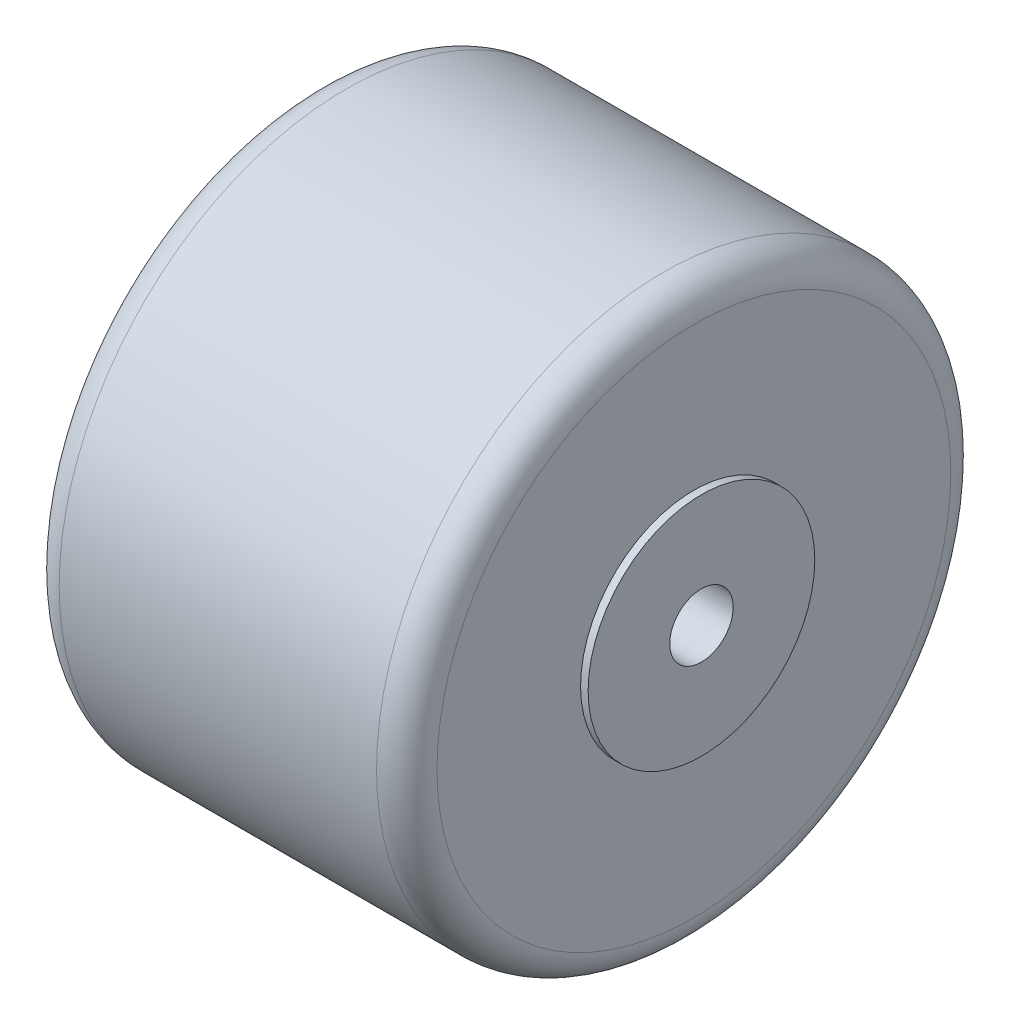
from build123d import *

# Parameters (mm, degrees)
M5_GEWINDEBOHRUNG2_D     = 4.2
M5_GEWINDEBOHRUNG2_DEPTH = 12
M5_GEWINDEBOHRUNG2_TIP   = 1.2618073
VERRUNDUNG1_R            = 2


with BuildPart() as part:
    # Skizze1 → Rotation1 (revolve)
    with BuildSketch(Plane.XY):
        Polygon((0, 0), (0, 7.5), (0.5, 7.5), (0.5, 19), (25.5, 19), (25.5, 7.5), (26, 7.5), (26, 0), align=None)
    revolve(axis=Axis((0, 0, 0), (1, 0, 0)))

    # Skizze2 → M5 Gewindebohrung1 (revolve, cut)
    with BuildSketch(Plane(origin=(26, 0, 0), x_dir=(0, 0, -1), z_dir=(0, 1, 0))):
        Polygon((0, 0), (0, 13.2618073), (2.1, 12), (2.1, 0), align=None)
    revolve(axis=Axis((32.35, 0, 0), (-1, 0, 0)), mode=Mode.SUBTRACT)

    # M5 Gewindebohrung2
    with Locations(Plane.ZY):
        with Locations((0, 0)):
            Hole(M5_GEWINDEBOHRUNG2_D / 2, depth=M5_GEWINDEBOHRUNG2_DEPTH)
            with Locations((0, 0, -(M5_GEWINDEBOHRUNG2_DEPTH + M5_GEWINDEBOHRUNG2_TIP / 2))):  # 118° drill point
                Cone(0, M5_GEWINDEBOHRUNG2_D / 2, M5_GEWINDEBOHRUNG2_TIP, mode=Mode.SUBTRACT)

    # Verrundung1
    verrundung1_edges = [part.edges().sort_by_distance(p)[0] for p in [
        (0.5, -19, 0),
        (25.5, -19, 0),
    ]]
    fillet(verrundung1_edges, radius=VERRUNDUNG1_R)


solid = part.part
